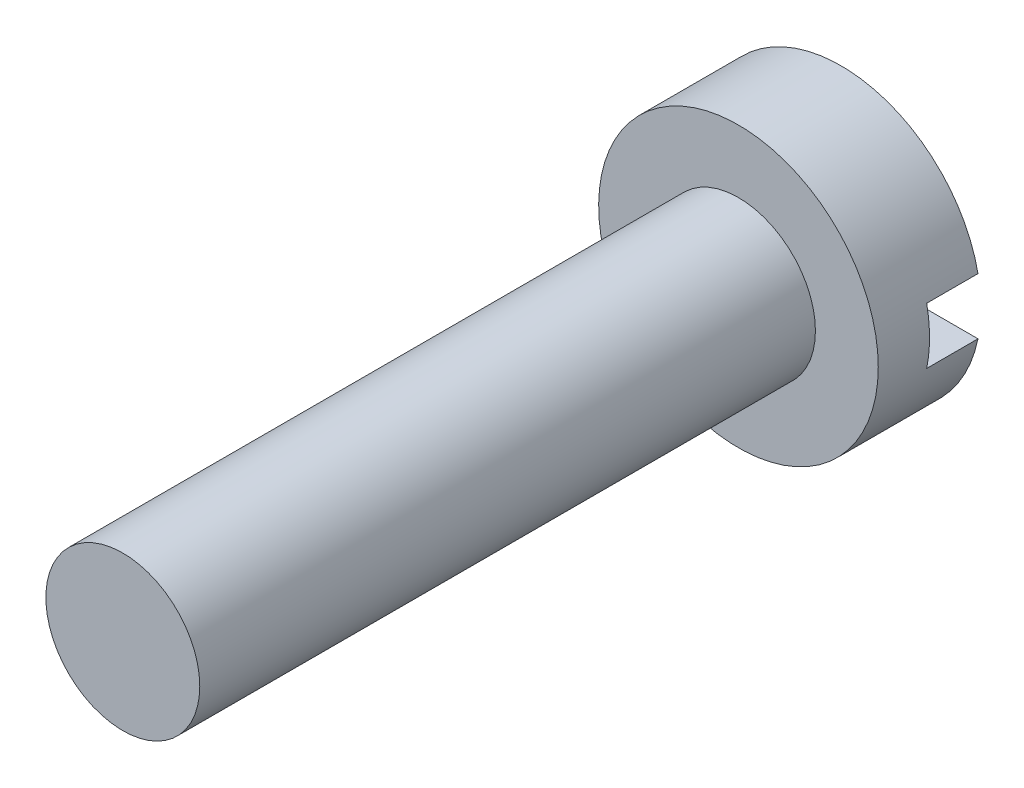
from build123d import *

# Parameters (mm, degrees)
SKETCH1_R          = 2.725
EXTRUDE1_DEPTH     = 2
CUT_EXTRUDE1_DEPTH = 1
SKETCH3_R          = 1.5
EXTRUDE2_DEPTH     = 12


with BuildPart() as part:
    # Sketch1 → Extrude1 (new body)
    with BuildSketch(Plane.XY):
        Circle(SKETCH1_R)
    extrude(amount=EXTRUDE1_DEPTH)

    # Sketch2 → Cut-Extrude1 (cut)
    with BuildSketch(Plane(origin=(0, 0, 0), x_dir=(-1, 0, 0), z_dir=(0, 0, -1))):
        Polygon((3.449801909, 0), (3.449801909, 0.55), (-3.901269584, 0.55), (-3.901269584, -0.55), (3.449801909, -0.55), align=None)
    extrude(amount=-CUT_EXTRUDE1_DEPTH, mode=Mode.SUBTRACT)

    # Sketch3 → Extrude2 (add)
    with BuildSketch(Plane.XY.offset(2)):
        Circle(SKETCH3_R)
    extrude(amount=EXTRUDE2_DEPTH)


solid = part.part
